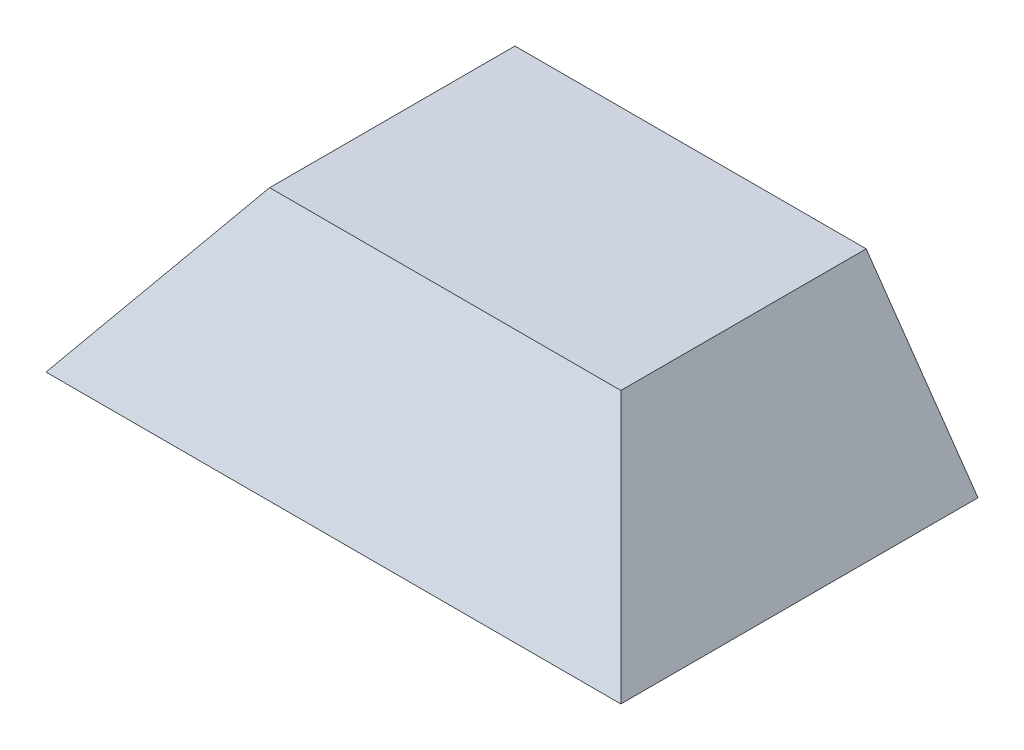
from build123d import *

# Parameters (mm, degrees)
CROQUIS1_W                  = 180
CROQUIS1_H                  = 129.33
SALIENTE_EXTRUIR1_DEPTH     = 50
CORTAR_EXTRUIR1_REACH       = 167.307
CORTAR_EXTRUIR2_REACH       = 199.691
VACIADO1_T                  = -4
SALIENTE_EXTRUIR4_DEPTH     = 102.576221704
CORTAR_EXTRUIR10_DEPTH      = 92.576221704
CROQUIS15_W                 = 55.416410159
CROQUIS15_H                 = 50
CORTAR_EXTRUIR11_DEPTH      = 146.333689347
CORTAR_EXTRUIR11_DEPTH_BACK = 146.333689347
SALIENTE_EXTRUIR6_REACH     = 181.671
CROQUIS19_W                 = 20
CROQUIS19_H                 = 20
CROQUIS20_W                 = 20
CROQUIS20_H                 = 5
CORTAR_EXTRUIR14_DEPTH      = 8
CORTAR_EXTRUIR15_REACH      = 121.61
CROQUIS22_R                 = 1.585


with BuildPart() as part:
    # Croquis1 → Saliente-Extruir1 (new body)
    with BuildSketch(Plane(origin=(0, 0, 0), x_dir=(1, 0, 0), z_dir=(0, 1, 0))):
        Rectangle(CROQUIS1_W, CROQUIS1_H)
    extrude(amount=SALIENTE_EXTRUIR1_DEPTH)

    # Croquis2 → Cortar-Extruir1 (cut, up to next)
    with BuildSketch(Plane.XY.offset(64.665), mode=Mode.PRIVATE) as cortar_extruir1_sk1:
        Polygon((90, 0), (54.98962309, 50), (90, 50), align=None)
    cortar_extruir1_tool1 = extrude(cortar_extruir1_sk1.sketch, amount=-CORTAR_EXTRUIR1_REACH, mode=Mode.PRIVATE) & part.part
    cortar_extruir1 = cortar_extruir1_tool1.solids().sort_by_distance((78.329874, 33.333333, 64.665))[0]
    add(cortar_extruir1, mode=Mode.SUBTRACT)

    # Cortar-Extruir2: up to this plane
    cortar_extruir2_end = Plane(origin=(90, 0, -64.666), z_dir=(-0.8191520442889952, -0.5735764363510412, 0))
    # Croquis4 → Cortar-Extruir2 (cut, up to the surface)
    with BuildSketch(Plane.ZY.offset(90), mode=Mode.PRIVATE) as cortar_extruir2_sk1:
        Polygon((-64.665, 0), (-29.65462309, 50), (-64.665, 50), align=None)
    cortar_extruir2_tool1 = split(extrude(cortar_extruir2_sk1.sketch, amount=-CORTAR_EXTRUIR2_REACH, mode=Mode.PRIVATE), bisect_by=cortar_extruir2_end, keep=Keep.BOTH, mode=Mode.PRIVATE)
    cortar_extruir2 = cortar_extruir2_tool1.solids().sort_by_distance((-90, 33.333333, -52.994874))[0]
    add(cortar_extruir2, mode=Mode.SUBTRACT)

    # Simetría2: Cortar-Extruir2 across plane
    add(cortar_extruir2.mirror(Plane.XY), mode=Mode.SUBTRACT)

    # Simetría1: Cortar-Extruir1 across plane
    add(cortar_extruir1.mirror(Plane(origin=(0, 0, 0), x_dir=(0, 0, 1), z_dir=(1, 0, 0))), mode=Mode.SUBTRACT)

    # Simetría1 at the second plane: Cortar-Extruir1 across plane
    add(cortar_extruir1.mirror(Plane.XY), mode=Mode.SUBTRACT)

    # Vaciado1
    vaciado1_openings = [part.faces().sort_by_distance(p)[0] for p in [
        (0, 0, 0),
    ]]
    offset(amount=VACIADO1_T, openings=vaciado1_openings, kind=Kind.INTERSECTION)

    # Croquis7 → Saliente-Extruir4 (add)
    with BuildSketch(Plane(origin=(0, 14.764441718, 0), x_dir=(-1, 0, 0), z_dir=(0, 0, -1))):
        Polygon((-54.98962309, 10.235558282), (-72.494811545, 10.235558282), (-54.98962309, 35.235558282), (54.98962309, 35.235558282), (72.494811545, 10.235558282), (54.98962309, 10.235558282), align=None)
    extrude(amount=SALIENTE_EXTRUIR4_DEPTH)

    # Croquis14 → Cortar-Extruir10 (cut)
    with BuildSketch(Plane.XY):
        Polygon((-85.116901645, 0), (-52.87991258, 46.039191676), (52.934417466, 46.039191676), (85.116901645, 0), align=None)
    extrude(amount=-CORTAR_EXTRUIR10_DEPTH, mode=Mode.SUBTRACT)

    # Croquis15 → Cortar-Extruir11 (cut, two sides)
    with BuildSketch(Plane(origin=(0, 0, 0), x_dir=(0, 0, -1), z_dir=(1, 0, 0))) as cortar_extruir11_sk:
        with Locations((74.868016625, 25)):
            Rectangle(CROQUIS15_W, CROQUIS15_H)
    extrude(amount=CORTAR_EXTRUIR11_DEPTH, mode=Mode.SUBTRACT)
    extrude(cortar_extruir11_sk.sketch, amount=-CORTAR_EXTRUIR11_DEPTH_BACK, mode=Mode.SUBTRACT)

    # Croquis19 → Saliente-Extruir6 (add, up to next)
    with BuildSketch(Plane(origin=(70, 0, 0), x_dir=(0, 0, -1), z_dir=(1, 0, 0)), mode=Mode.PRIVATE) as saliente_extruir6_sk1:
        with Locations((-1.703719293, 10)):
            Rectangle(CROQUIS19_W, CROQUIS19_H)
    saliente_extruir6_tool1 = extrude(saliente_extruir6_sk1.sketch, amount=SALIENTE_EXTRUIR6_REACH, mode=Mode.PRIVATE) - part.part
    saliente_extruir6 = saliente_extruir6_tool1.solids().sort_by_distance((70, 10, 1.703719))[0]
    add(saliente_extruir6)

    # Croquis20 → Cortar-Extruir14 (cut)
    with BuildSketch(Plane.ZY.offset(-70)):
        with Locations((1.703719293, 7.5)):
            Rectangle(CROQUIS20_W, CROQUIS20_H)
    cortar_extruir14 = extrude(amount=-CORTAR_EXTRUIR14_DEPTH, mode=Mode.SUBTRACT)

    # Croquis22 → Cortar-Extruir15 (cut, up to next)
    with BuildSketch(Plane(origin=(0, 5, 0), x_dir=(1, 0, 0), z_dir=(0, 1, 0)), mode=Mode.PRIVATE) as cortar_extruir15_sk1:
        with Locations(Location((74, -1.703719293, 0), (0, 0, 270))):
            Circle(CROQUIS22_R)
    cortar_extruir15_tool1 = extrude(cortar_extruir15_sk1.sketch, amount=-CORTAR_EXTRUIR15_REACH, mode=Mode.PRIVATE) & part.part
    cortar_extruir15 = cortar_extruir15_tool1.solids().sort_by_distance((74, 5, 1.703719))[0]
    add(cortar_extruir15, mode=Mode.SUBTRACT)

    # Simetría3: Saliente-Extruir6, Cortar-Extruir14, Cortar-Extruir15 across plane
    add(saliente_extruir6.mirror(Plane(origin=(0, 0, 0), x_dir=(0, 0, 1), z_dir=(1, 0, 0))))
    add(cortar_extruir14.mirror(Plane(origin=(0, 0, 0), x_dir=(0, 0, 1), z_dir=(1, 0, 0))), mode=Mode.SUBTRACT)
    add(cortar_extruir15.mirror(Plane(origin=(0, 0, 0), x_dir=(0, 0, 1), z_dir=(1, 0, 0))), mode=Mode.SUBTRACT)


solid = part.part
